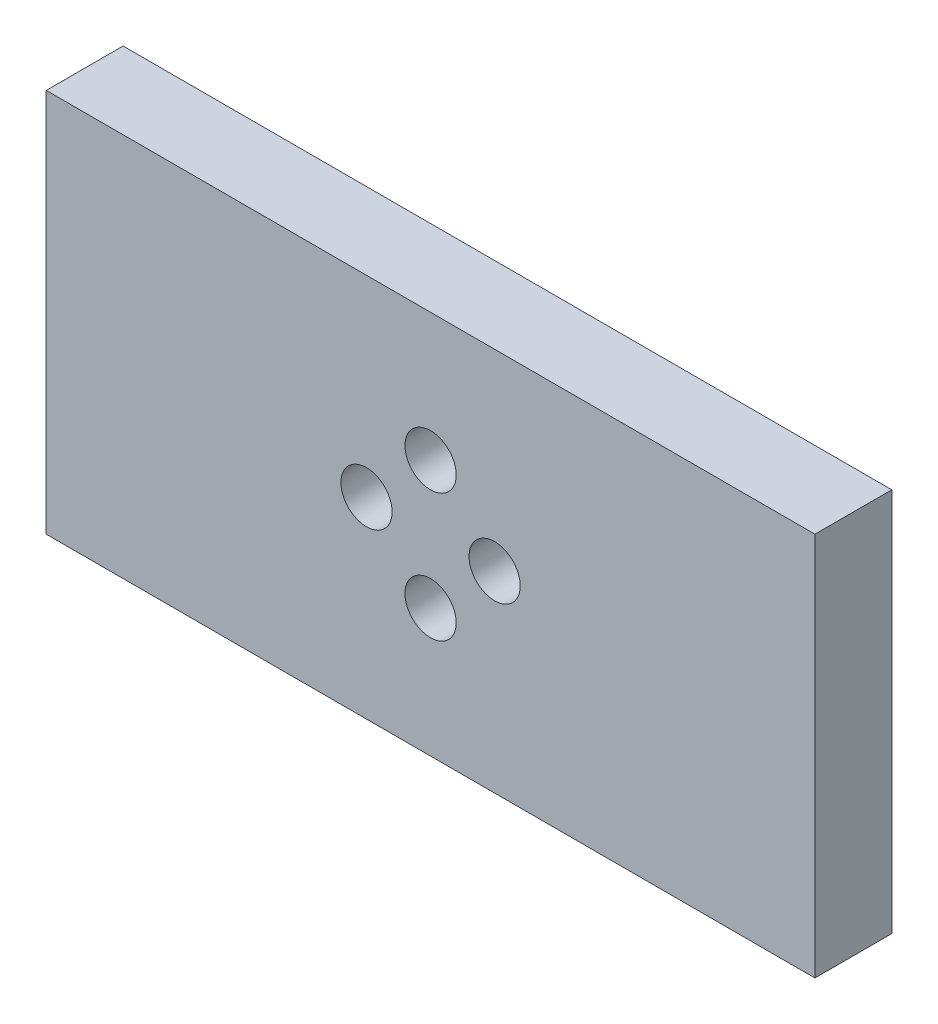
from build123d import *

# Parameters (mm, degrees)
SKETCH1_W           = 30
SKETCH1_H           = 15
BOSS_EXTRUDE1_DEPTH = 3
SKETCH2_R           = 1
CUT_EXTRUDE1_DEPTH  = 10


with BuildPart() as part:
    # Sketch1 → Boss-Extrude1 (new body)
    with BuildSketch(Plane.XY):
        Rectangle(SKETCH1_W, SKETCH1_H)
    extrude(amount=BOSS_EXTRUDE1_DEPTH)

    # Sketch2 → Cut-Extrude1 (cut)
    with BuildSketch(Plane.XY.offset(3)):
        with Locations((0, 2.5)):
            Circle(SKETCH2_R)
        with Locations((2.5, 0)):
            Circle(SKETCH2_R)
        with Locations((0, -2.5)):
            Circle(SKETCH2_R)
        with Locations((-2.5, 0)):
            Circle(SKETCH2_R)
    extrude(amount=-CUT_EXTRUDE1_DEPTH, mode=Mode.SUBTRACT)


solid = part.part
